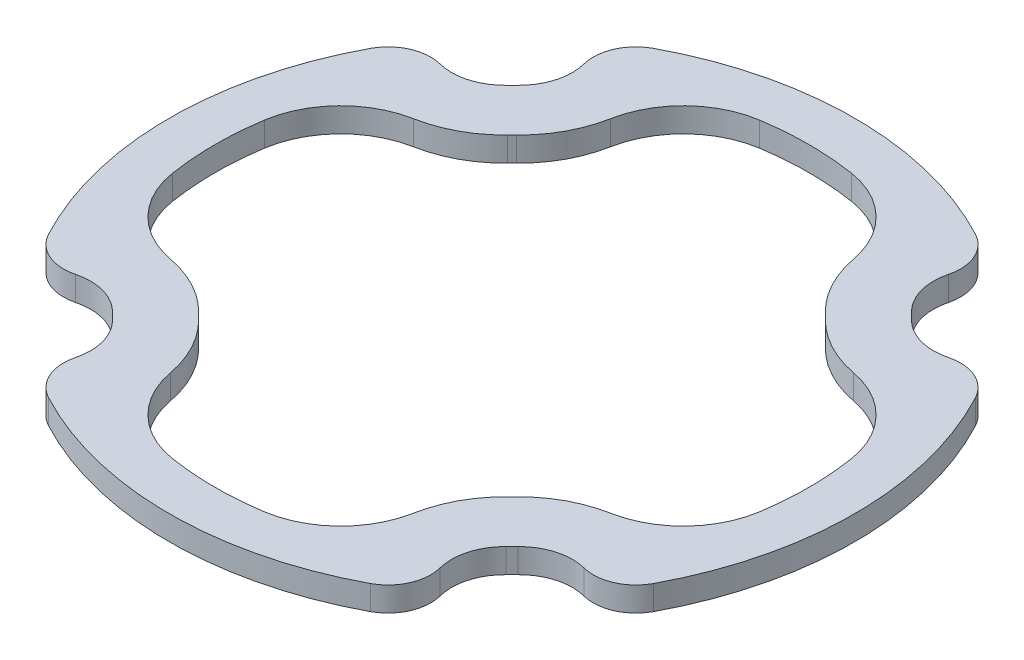
from build123d import *

# Parameters (mm, degrees)
BOSS_EXTRUDE1_DEPTH = 1.6
CUT_EXTRUDE2_DEPTH  = 2.6


with BuildPart() as part:
    # Internal Slab → Boss-Extrude1 (new body)
    with BuildSketch(Plane(origin=(0, 0, 0), x_dir=(1, 0, 0), z_dir=(0, 1, 0))):
        with BuildLine():
            ThreePointArc((19.864398082, 10.566725549), (18.521398428, 11.814512636), (16.694380928, 11.964937844))
            ThreePointArc((16.694380928, 11.964937844), (14.875391632, 11.986370035), (13.312847331, 12.91784022))
            ThreePointArc((13.312847331, 12.91784022), (13.116830791, 13.116830791), (12.91784022, 13.312847331))
            ThreePointArc((12.91784022, 13.312847331), (11.986370035, 14.875391632), (11.964937844, 16.694380928))
            ThreePointArc((11.964937844, 16.694380928), (12.030759646, 17.039737643), (12.052815994, 17.390618375))
            ThreePointArc((12.052815994, 17.390618375), (11.652730082, 18.833536499), (10.566725549, 19.864398082))
            ThreePointArc((10.566725549, 19.864398082), (0, 22.5), (-10.566725549, 19.864398082))
            ThreePointArc((-10.566725549, 19.864398082), (-11.814512636, 18.521398428), (-11.964937844, 16.694380928))
            ThreePointArc((-11.964937844, 16.694380928), (-11.986370035, 14.875391632), (-12.91784022, 13.312847331))
            ThreePointArc((-12.91784022, 13.312847331), (-13.116830791, 13.116830791), (-13.312847331, 12.91784022))
            ThreePointArc((-13.312847331, 12.91784022), (-14.875391632, 11.986370035), (-16.694380928, 11.964937844))
            ThreePointArc((-16.694380928, 11.964937844), (-17.039737643, 12.030759646), (-17.390618375, 12.052815994))
            ThreePointArc((-17.390618375, 12.052815994), (-18.833536499, 11.652730082), (-19.864398082, 10.566725549))
            ThreePointArc((-19.864398082, 10.566725549), (-22.5, 0), (-19.864398082, -10.566725549))
            ThreePointArc((-19.864398082, -10.566725549), (-18.521398428, -11.814512636), (-16.694380928, -11.964937844))
            ThreePointArc((-16.694380928, -11.964937844), (-14.875391632, -11.986370035), (-13.312847331, -12.91784022))
            ThreePointArc((-13.312847331, -12.91784022), (-13.116830791, -13.116830791), (-12.91784022, -13.312847331))
            ThreePointArc((-12.91784022, -13.312847331), (-11.986370035, -14.875391632), (-11.964937844, -16.694380928))
            ThreePointArc((-11.964937844, -16.694380928), (-12.030759646, -17.039737643), (-12.052815994, -17.390618375))
            ThreePointArc((-12.052815994, -17.390618375), (-11.652730082, -18.833536499), (-10.566725549, -19.864398082))
            ThreePointArc((-10.566725549, -19.864398082), (0, -22.5), (10.566725549, -19.864398082))
            ThreePointArc((10.566725549, -19.864398082), (11.814512636, -18.521398428), (11.964937844, -16.694380928))
            ThreePointArc((11.964937844, -16.694380928), (11.986370035, -14.875391632), (12.91784022, -13.312847331))
            ThreePointArc((12.91784022, -13.312847331), (13.116830791, -13.116830791), (13.312847331, -12.91784022))
            ThreePointArc((13.312847331, -12.91784022), (14.875391632, -11.986370035), (16.694380928, -11.964937844))
            ThreePointArc((16.694380928, -11.964937844), (17.039737643, -12.030759646), (17.390618375, -12.052815994))
            ThreePointArc((17.390618375, -12.052815994), (18.833536499, -11.652730082), (19.864398082, -10.566725549))
            ThreePointArc((19.864398082, -10.566725549), (22.5, 0), (19.864398082, 10.566725549))
        make_face()
    extrude(amount=BOSS_EXTRUDE1_DEPTH)

    # Sketch3 → Cut-Extrude2 (cut, through all)
    with BuildSketch(Plane(origin=(0, 0, 0), x_dir=(1, 0, 0), z_dir=(0, 1, 0))):
        with BuildLine():
            ThreePointArc((-14.443108961, 7.983520749), (-17.643874139, 6.264479657), (-19.265757154, 3.013403606))
            ThreePointArc((-19.265757154, 3.013403606), (-19.441351091, 1.511247085), (-19.5, 0))
            ThreePointArc((-19.5, 0), (-19.441351091, -1.511247085), (-19.265757154, -3.013403606))
            ThreePointArc((-19.265757154, -3.013403606), (-17.643874139, -6.264479657), (-14.443108961, -7.983520749))
            ThreePointArc((-14.443108961, -7.983520749), (-12.276076656, -8.747806411), (-10.442152488, -10.132322113))
            ThreePointArc((-10.442152488, -10.132322113), (-10.288403666, -10.288403666), (-10.132322113, -10.442152488))
            ThreePointArc((-10.132322113, -10.442152488), (-8.747806411, -12.276076656), (-7.983520749, -14.443108961))
            ThreePointArc((-7.983520749, -14.443108961), (-6.264479657, -17.643874139), (-3.013403606, -19.265757154))
            ThreePointArc((-3.013403606, -19.265757154), (-1.511247085, -19.441351091), (0, -19.5))
            ThreePointArc((0, -19.5), (1.511247085, -19.441351091), (3.013403606, -19.265757154))
            ThreePointArc((3.013403606, -19.265757154), (6.264479657, -17.643874139), (7.983520749, -14.443108961))
            ThreePointArc((7.983520749, -14.443108961), (8.747806411, -12.276076656), (10.132322113, -10.442152488))
            ThreePointArc((10.132322113, -10.442152488), (10.288403666, -10.288403666), (10.442152488, -10.132322113))
            ThreePointArc((10.442152488, -10.132322113), (12.276076656, -8.747806411), (14.443108961, -7.983520749))
            ThreePointArc((14.443108961, -7.983520749), (17.643874139, -6.264479657), (19.265757154, -3.013403606))
            ThreePointArc((19.265757154, -3.013403606), (19.441351091, -1.511247085), (19.5, 0))
            ThreePointArc((19.5, 0), (19.441351091, 1.511247085), (19.265757154, 3.013403606))
            ThreePointArc((19.265757154, 3.013403606), (17.643874139, 6.264479657), (14.443108961, 7.983520749))
            ThreePointArc((14.443108961, 7.983520749), (12.276076656, 8.747806411), (10.442152488, 10.132322113))
            ThreePointArc((10.442152488, 10.132322113), (10.288403666, 10.288403666), (10.132322113, 10.442152488))
            ThreePointArc((10.132322113, 10.442152488), (8.747806411, 12.276076656), (7.983520749, 14.443108961))
            ThreePointArc((7.983520749, 14.443108961), (6.264479657, 17.643874139), (3.013403606, 19.265757154))
            ThreePointArc((3.013403606, 19.265757154), (1.511247085, 19.441351091), (0, 19.5))
            ThreePointArc((0, 19.5), (-1.511247085, 19.441351091), (-3.013403606, 19.265757154))
            ThreePointArc((-3.013403606, 19.265757154), (-6.264479657, 17.643874139), (-7.983520749, 14.443108961))
            ThreePointArc((-7.983520749, 14.443108961), (-8.747806411, 12.276076656), (-10.132322113, 10.442152488))
            ThreePointArc((-10.132322113, 10.442152488), (-10.288403666, 10.288403666), (-10.442152488, 10.132322113))
            ThreePointArc((-10.442152488, 10.132322113), (-12.276076656, 8.747806411), (-14.443108961, 7.983520749))
        make_face()
    extrude(amount=CUT_EXTRUDE2_DEPTH, mode=Mode.SUBTRACT)


solid = part.part
